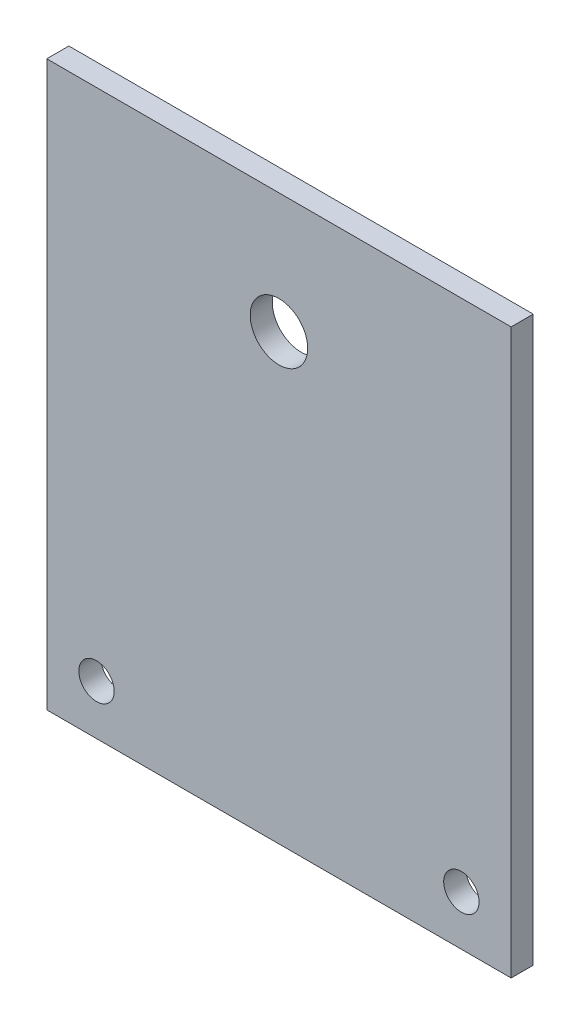
from build123d import *

# Parameters (mm, degrees)
SKETCH_1_W      = 42
SKETCH_1_H      = 51
SKETCH_1_R      = 1.6
SKETCH_1_R_2    = 2.6
EXTRUDE_1_DEPTH = 2


with BuildPart() as part:
    # ｽｹｯﾁ1 → ﾎﾞｽ - 押し出し1 (new body)
    with BuildSketch(Plane.XY):
        Rectangle(SKETCH_1_W, SKETCH_1_H)
        with Locations((-16.5, -21)):
            Circle(SKETCH_1_R, mode=Mode.SUBTRACT)
        with Locations((16.5, -21)):
            Circle(SKETCH_1_R, mode=Mode.SUBTRACT)
        with Locations((0, 14.62)):
            Circle(SKETCH_1_R_2, mode=Mode.SUBTRACT)
    extrude(amount=EXTRUDE_1_DEPTH)


solid = part.part
